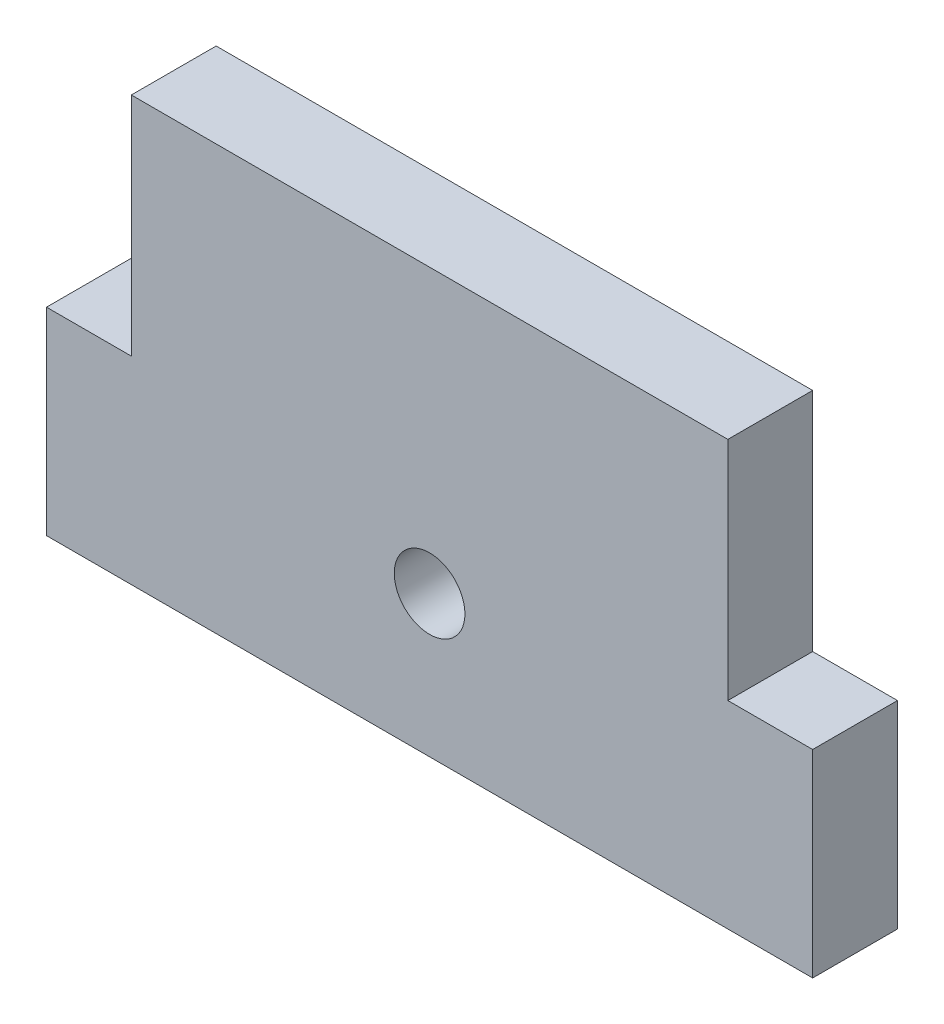
from build123d import *

# Parameters (mm, degrees)
SKETCH1_R           = 2.5
BOSS_EXTRUDE1_DEPTH = 6


with BuildPart() as part:
    # Sketch1 → Boss-Extrude1 (new body)
    with BuildSketch(Plane.XY):
        Polygon((6, 30), (48.2, 30), (48.2, 14), (54.2, 14), (54.2, 0), (0, 0), (0, 14), (6, 14), align=None)
        with Locations((27.1, 10)):
            Circle(SKETCH1_R, mode=Mode.SUBTRACT)
    extrude(amount=BOSS_EXTRUDE1_DEPTH)


solid = part.part
